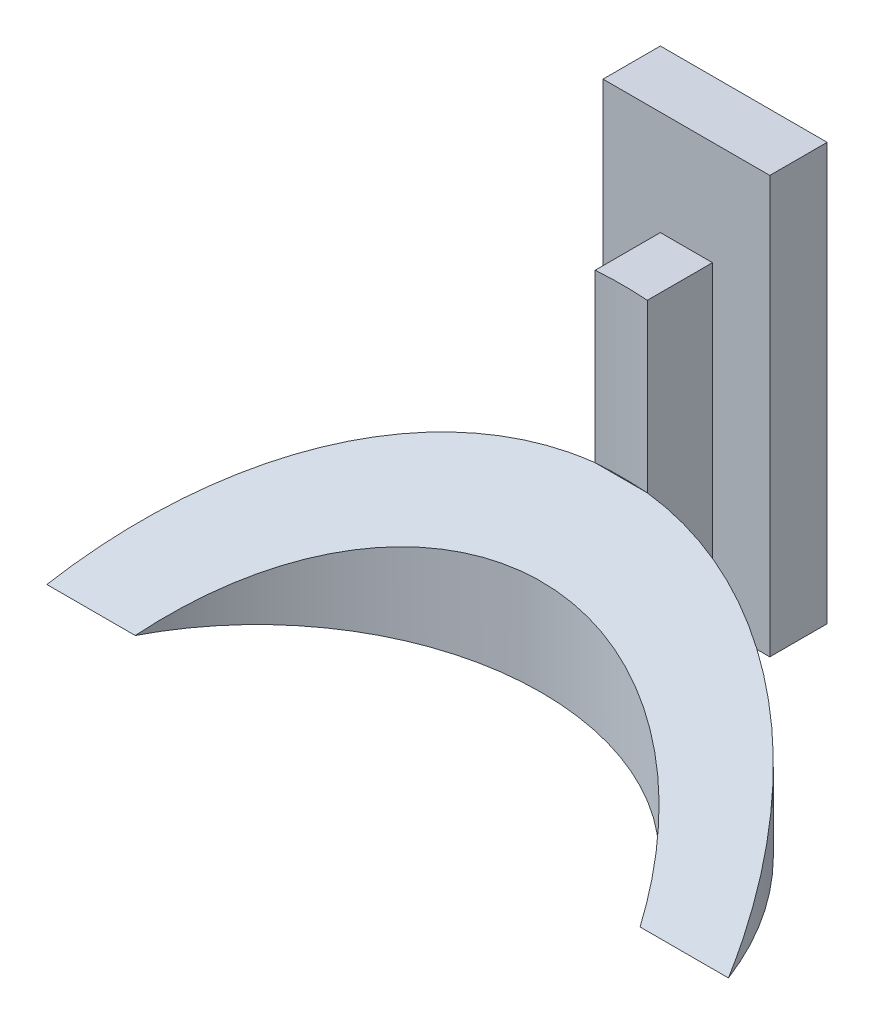
from build123d import *

# Parameters (mm, degrees)
SKETCH1_W               = 16
SKETCH1_H               = 5
BOSS_EXTRUDE1_DEPTH     = 30
BOSS_EXTRUDE2_DEPTH     = 14
CUT_EXTRUDE1_DEPTH      = 33.691742077
CUT_EXTRUDE1_DEPTH_BACK = 33.691742077
BOSS_EXTRUDE3_START     = 30
SKETCH1_3_W             = 16
SKETCH1_3_H             = 5
BOSS_EXTRUDE3_DEPTH     = 10
SKETCH5_W               = 16
SKETCH5_H               = 0.5
BOSS_EXTRUDE4_DEPTH     = 40


with BuildPart() as part:
    # Sketch1 → Boss-Extrude1 (new body)
    with BuildSketch(Plane(origin=(0, 0, 0), x_dir=(1, 0, 0), z_dir=(0, 1, 0))):
        Rectangle(SKETCH1_W, SKETCH1_H)
        with BuildLine():
            Line((2.5, -9.25), (2.5, -2.5))
            Line((2.5, -2.5), (-2.5, -2.5))
            Line((-2.5, -2.5), (-2.5, -9.25))
            ThreePointArc((-2.5, -9.25), (0, -9.160600109), (2.5, -9.25))
        make_face()
    extrude(amount=BOSS_EXTRUDE1_DEPTH)

    # Sketch2 → Boss-Extrude2 (add)
    with BuildSketch(Plane(origin=(0, 0, 0), x_dir=(1, 0, 0), z_dir=(0, 1, 0))):
        with BuildLine():
            ThreePointArc((32.691742077, -31.660600109), (0, -9.160600109), (-32.691742077, -31.660600109))
            Line((-32.691742077, -31.660600109), (-24.213890642, -31.660600109))
            ThreePointArc((-24.213890642, -31.660600109), (0, -16.910600109), (24.213890642, -31.660600109))
            Line((24.213890642, -31.660600109), (32.691742077, -31.660600109))
        make_face()
    extrude(amount=BOSS_EXTRUDE2_DEPTH)

    # Sketch3 → Cut-Extrude1 (cut, two sides)
    with BuildSketch(Plane(origin=(0, 0, 0), x_dir=(0, 0, -1), z_dir=(1, 0, 0))) as cut_extrude1_sk:
        Polygon((-9.25, 14), (-31.660600109, 14), (-31.660600109, 0), align=None)
    extrude(amount=CUT_EXTRUDE1_DEPTH, mode=Mode.SUBTRACT)
    extrude(cut_extrude1_sk.sketch, amount=-CUT_EXTRUDE1_DEPTH_BACK, mode=Mode.SUBTRACT)

    # Sketch1_3 → Boss-Extrude3 (add)
    with BuildSketch(Plane(origin=(0, 0, 0), x_dir=(1, 0, 0), z_dir=(0, 1, 0)).offset(BOSS_EXTRUDE3_START)):
        Rectangle(SKETCH1_3_W, SKETCH1_3_H)
    extrude(amount=BOSS_EXTRUDE3_DEPTH)

    # Sketch5 → Boss-Extrude4 (add)
    with BuildSketch(Plane(origin=(0, 40, 0), x_dir=(1, 0, 0), z_dir=(0, 1, 0))):
        with Locations((0, -2.75)):
            Rectangle(SKETCH5_W, SKETCH5_H)
    extrude(amount=-BOSS_EXTRUDE4_DEPTH)


solid = part.part
